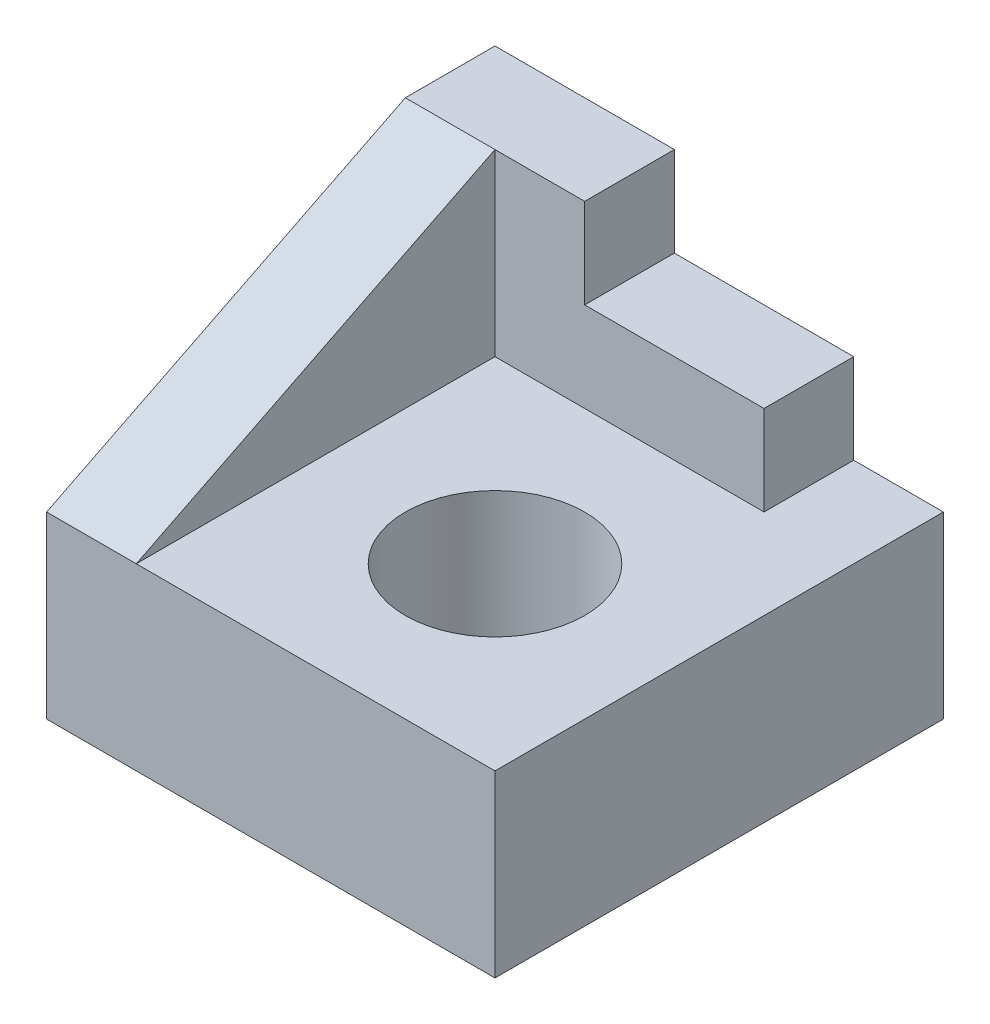
from build123d import *

# Parameters (mm, degrees)
SKETCH_1_R          = 5
EXTRUDE_1_DEPTH     = 10
SKETCH_1_3_W        = 10
SKETCH_1_3_H        = 5
EXTRUDE_2_DEPTH     = 15
EXTRUDE_3_DEPTH     = 20
CUT_EXTRUDE_1_DEPTH = 20


with BuildPart() as part:
    # 草圖1 → 填料-伸長1 (new body)
    with BuildSketch(Plane(origin=(0, 0, 0), x_dir=(1, 0, 0), z_dir=(0, 1, 0))):
        Polygon((10, 15), (5, 15), (5, 10), (-5, 10), (-10, 10), (-10, -10), (10, -10), align=None)
        Circle(SKETCH_1_R, mode=Mode.SUBTRACT)
    extrude(amount=EXTRUDE_1_DEPTH)

    # 草圖1<3> → 填料-伸長2 (add)
    with BuildSketch(Plane(origin=(0, 0, 0), x_dir=(1, 0, 0), z_dir=(0, 1, 0))):
        with Locations((0, 12.5)):
            Rectangle(SKETCH_1_3_W, SKETCH_1_3_H)
    extrude(amount=EXTRUDE_2_DEPTH)

    # 草圖1<4> → 填料-伸長3 (add)
    with BuildSketch(Plane(origin=(0, 0, 0), x_dir=(1, 0, 0), z_dir=(0, 1, 0))):
        Polygon((-5, 15), (-15, 15), (-15, -10), (-10, -10), (-10, 10), (-5, 10), align=None)
    extrude(amount=EXTRUDE_3_DEPTH)

    # 草圖2 → 除料-伸長1 (cut)
    with BuildSketch(Plane(origin=(-10, 0, 0), x_dir=(0, 0, -1), z_dir=(1, 0, 0))):
        Polygon((-10, 10), (10, 20), (-10, 20), align=None)
    extrude(amount=-CUT_EXTRUDE_1_DEPTH, mode=Mode.SUBTRACT)


solid = part.part
